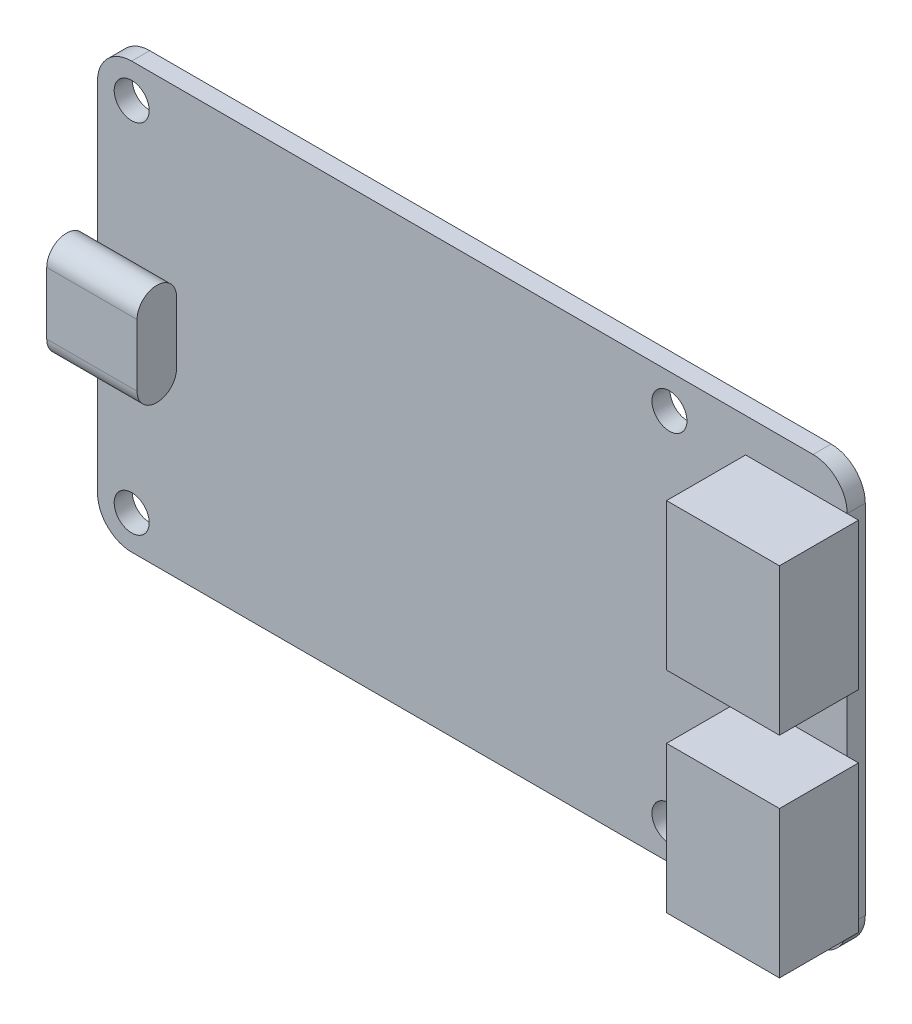
from build123d import *

# Parameters (mm, degrees)
ESBO_O1_R                     = 1.55
RESSALTO_EXTRUS_O1_DEPTH      = 1.6
ESBO_O2_W                     = 10
ESBO_O2_H                     = 13
RESSALTO_EXTRUS_O2_DEPTH      = 7
RESSALTO_EXTRUS_O3_DEPTH      = 1
RESSALTO_EXTRUS_O3_DEPTH_BACK = 7


with BuildPart() as part:
    # Esboço1 → Ressalto-extrusão1 (new body)
    with BuildSketch(Plane.XY):
        with BuildLine():
            Line((-30.175, 18.835), (30.175, 18.835))
            ThreePointArc((30.175, 18.835), (32.313998013, 17.948998013), (33.2, 15.81))
            Line((33.2, 15.81), (33.2, -15.81))
            ThreePointArc((33.2, -15.81), (32.313998013, -17.948998013), (30.175, -18.835))
            Line((30.175, -18.835), (-30.175, -18.835))
            ThreePointArc((-30.175, -18.835), (-32.313998013, -17.948998013), (-33.2, -15.81))
            Line((-33.2, -15.81), (-33.2, 15.81))
            ThreePointArc((-33.2, 15.81), (-32.313998013, 17.948998013), (-30.175, 18.835))
        make_face()
        with Locations((-30.175, 15.81)):
            Circle(ESBO_O1_R, mode=Mode.SUBTRACT)
        with Locations((-30.175, -15.81)):
            Circle(ESBO_O1_R, mode=Mode.SUBTRACT)
        with Locations((17.455, 15.81)):
            Circle(ESBO_O1_R, mode=Mode.SUBTRACT)
        with Locations((17.455, -15.81)):
            Circle(ESBO_O1_R, mode=Mode.SUBTRACT)
    extrude(amount=RESSALTO_EXTRUS_O1_DEPTH)

    # Esboço2 → Ressalto-extrusão2 (add)
    with BuildSketch(Plane.XY.offset(1.6)):
        with Locations((29.2, 9.31)):
            Rectangle(ESBO_O2_W, ESBO_O2_H)
        with Locations((29.2, -9.31)):
            Rectangle(ESBO_O2_W, ESBO_O2_H)
    extrude(amount=RESSALTO_EXTRUS_O2_DEPTH)

    # Esboço3 → Ressalto-extrusão3 (add, two sides)
    with BuildSketch(Plane.ZY.offset(33.2)) as ressalto_extrus_o3_sk:
        with BuildLine():
            Line((5.1, 2.75), (5.1, -2.75))
            ThreePointArc((5.1, -2.75), (3.35, -4.5), (1.6, -2.75))
            Line((1.6, -2.75), (1.6, 2.75))
            ThreePointArc((1.6, 2.75), (3.35, 4.5), (5.1, 2.75))
        make_face()
    extrude(amount=RESSALTO_EXTRUS_O3_DEPTH)
    extrude(ressalto_extrus_o3_sk.sketch, amount=-RESSALTO_EXTRUS_O3_DEPTH_BACK)


solid = part.part
